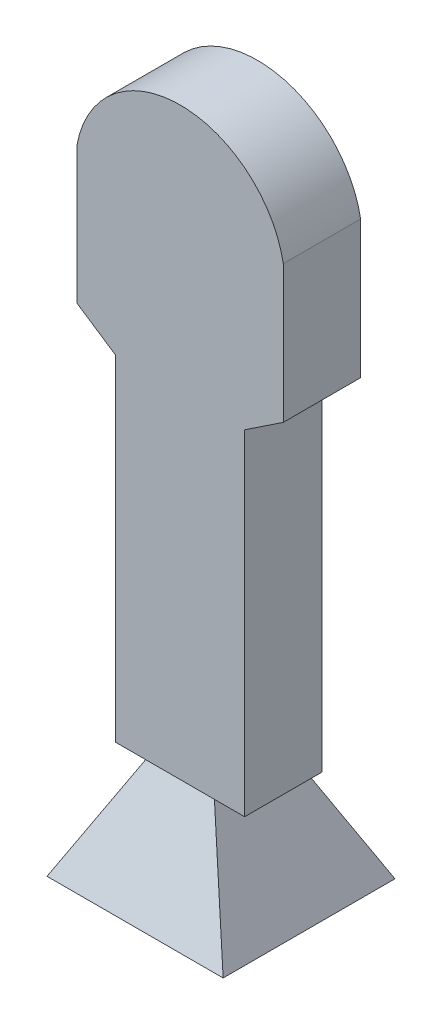
from build123d import *

# Parameters (mm, degrees)
RESSALTO_EXTRUS_O2_DEPTH      = 4.5
RESSALTO_EXTRUS_O2_DEPTH_BACK = 4.5
CORTE_EXTRUS_O1_DEPTH         = 3.5
CORTE_EXTRUS_O1_DEPTH_BACK    = 3.5
RESSALTO_EXTRUS_O3_DEPTH      = 10.5
RESSALTO_EXTRUS_O3_DEPTH_BACK = 10
CORTE_EXTRUS_O2_DEPTH         = 20
CORTE_EXTRUS_O2_DEPTH_BACK    = 18.5
ESBO_O6_W                     = 3.02122436
ESBO_O6_H                     = 3.325672956
CORTE_EXTRUS_O3_DEPTH         = 17
CORTE_EXTRUS_O3_DEPTH_BACK    = 12.5


with BuildPart() as part:
    # Esboço1 → Ressalto-extrusão2 (new body, two sides)
    with BuildSketch(Plane.XY) as ressalto_extrus_o2_sk:
        with BuildLine():
            Line((-12, 1), (-12, -15))
            Line((-12, -15), (-7.5, -18))
            Line((-7.5, -18), (-7.5, -57))
            Line((-7.5, -57), (-4, -57))
            Line((-4, -57), (-10, -69))
            Line((-10, -69), (10, -69))
            Line((10, -69), (4, -57))
            Line((4, -57), (7.5, -57))
            Line((7.5, -57), (7.5, -18))
            Line((7.5, -18), (12, -15))
            Line((12, -15), (12, 1))
            ThreePointArc((12, 1), (0, 10.990932971), (-12, 1))
        make_face()
    extrude(amount=RESSALTO_EXTRUS_O2_DEPTH)
    extrude(ressalto_extrus_o2_sk.sketch, amount=-RESSALTO_EXTRUS_O2_DEPTH_BACK)

    # Esboço2 → Corte-extrusão1 (cut, two sides)
    with BuildSketch(Plane.XY) as corte_extrus_o1_sk:
        with BuildLine():
            Line((-8.5, -68), (8.5, -68))
            Line((8.5, -68), (3, -57.063736363))
            Line((3, -57.063736363), (3, -56.109442195))
            Line((3, -56.109442195), (6.5, -56.109442195))
            Line((6.5, -56.109442195), (6.5, -17.135100905))
            Line((6.5, -17.135100905), (11, -14))
            Line((11, -14), (11, 0))
            ThreePointArc((11, 0), (0, 9.976174937), (-11, 0))
            Line((-11, 0), (-11, -14))
            Line((-11, -14), (-6.5, -17.135100905))
            Line((-6.5, -17.135100905), (-6.5, -56.109442195))
            Line((-6.5, -56.109442195), (-3, -56.109442195))
            Line((-3, -56.109442195), (-3, -57.063736363))
            Line((-3, -57.063736363), (-8.5, -68))
        make_face()
    extrude(amount=CORTE_EXTRUS_O1_DEPTH, mode=Mode.SUBTRACT)
    extrude(corte_extrus_o1_sk.sketch, amount=-CORTE_EXTRUS_O1_DEPTH_BACK, mode=Mode.SUBTRACT)

    # Esboço4 → Ressalto-extrusão3 (add, two sides)
    with BuildSketch(Plane(origin=(0, 0, 0), x_dir=(0, 0, -1), z_dir=(1, 0, 0))) as ressalto_extrus_o3_sk:
        Polygon((0, -69), (10, -69), (4.5, -57), (-4.5, -57), (-10, -69), align=None)
    extrude(amount=RESSALTO_EXTRUS_O3_DEPTH)
    extrude(ressalto_extrus_o3_sk.sketch, amount=-RESSALTO_EXTRUS_O3_DEPTH_BACK)

    # Esboço5 → Corte-extrusão2 (cut, two sides)
    with BuildSketch(Plane.XY) as corte_extrus_o2_sk:
        Polygon((-4.015865961, -57), (-10, -69), (-10, -57), align=None)
        Polygon((3.984134039, -57), (10.5, -69), (10.5, -57), align=None)
    extrude(amount=CORTE_EXTRUS_O2_DEPTH, mode=Mode.SUBTRACT)
    extrude(corte_extrus_o2_sk.sketch, amount=-CORTE_EXTRUS_O2_DEPTH_BACK, mode=Mode.SUBTRACT)

    # Esboço6 → Corte-extrusão3 (cut, two sides)
    with BuildSketch(Plane(origin=(0, -69, 0), x_dir=(-1, 0, 0), z_dir=(0, -1, 0))) as corte_extrus_o3_sk:
        Rectangle(ESBO_O6_W, ESBO_O6_H)
    extrude(amount=CORTE_EXTRUS_O3_DEPTH, mode=Mode.SUBTRACT)
    extrude(corte_extrus_o3_sk.sketch, amount=-CORTE_EXTRUS_O3_DEPTH_BACK, mode=Mode.SUBTRACT)


solid = part.part
